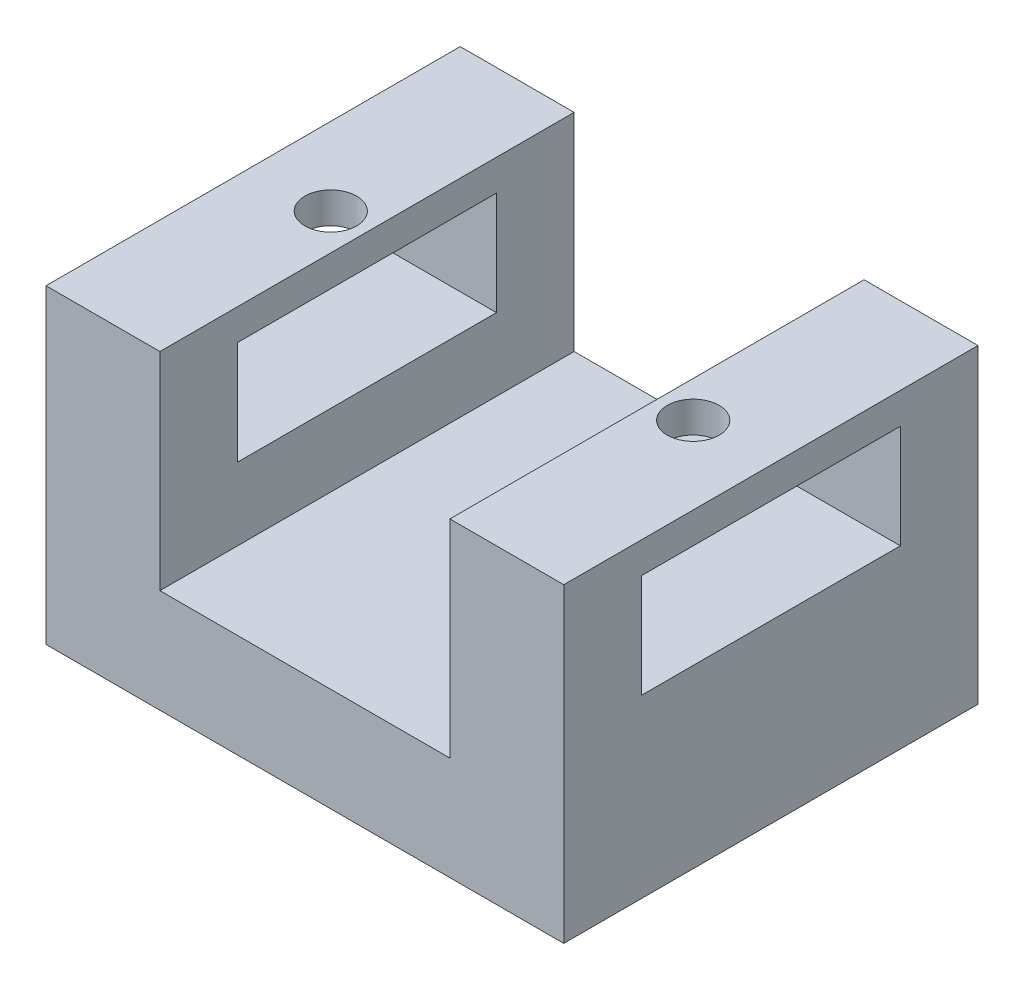
from build123d import *

# Parameters (mm, degrees)
SKETCH1_W           = 50
SKETCH1_H           = 40
BOSS_EXTRUDE1_DEPTH = 10
SKETCH3_W           = 11
SKETCH3_H           = 40
BOSS_EXTRUDE2_DEPTH = 20
SKETCH4_W           = 25
SKETCH4_H           = 10
CUT_EXTRUDE1_DEPTH  = 51
SKETCH5_R           = 2.5
CUT_EXTRUDE2_DEPTH  = 13


with BuildPart() as part:
    # Sketch1 → Boss-Extrude1 (new body)
    with BuildSketch(Plane(origin=(0, 0, 0), x_dir=(1, 0, 0), z_dir=(0, 1, 0))):
        with Locations((25, 20)):
            Rectangle(SKETCH1_W, SKETCH1_H)
    extrude(amount=BOSS_EXTRUDE1_DEPTH)

    # Sketch3 → Boss-Extrude2 (add)
    with BuildSketch(Plane(origin=(0, 10, 0), x_dir=(1, 0, 0), z_dir=(0, 1, 0))):
        with Locations((5.5, 20)):
            Rectangle(SKETCH3_W, SKETCH3_H)
    boss_extrude2 = extrude(amount=BOSS_EXTRUDE2_DEPTH)

    # Mirror1: Boss-Extrude2 across plane
    add(boss_extrude2.mirror(Plane.ZY.offset(-25)))

    # Sketch4 → Cut-Extrude1 (cut, through all)
    with BuildSketch(Plane(origin=(50, 0, 0), x_dir=(0, 0, -1), z_dir=(1, 0, 0))):
        with Locations((20, 22)):
            Rectangle(SKETCH4_W, SKETCH4_H)
    extrude(amount=-CUT_EXTRUDE1_DEPTH, mode=Mode.SUBTRACT)

    # Sketch5 → Cut-Extrude2 (cut)
    with BuildSketch(Plane(origin=(0, 30, 0), x_dir=(1, 0, 0), z_dir=(0, 1, 0))):
        with Locations((7.5, 20)):
            Circle(SKETCH5_R)
    cut_extrude2 = extrude(amount=-CUT_EXTRUDE2_DEPTH, mode=Mode.SUBTRACT)

    # Mirror2: Cut-Extrude2 across plane
    add(cut_extrude2.mirror(Plane.ZY.offset(-25)), mode=Mode.SUBTRACT)


solid = part.part
